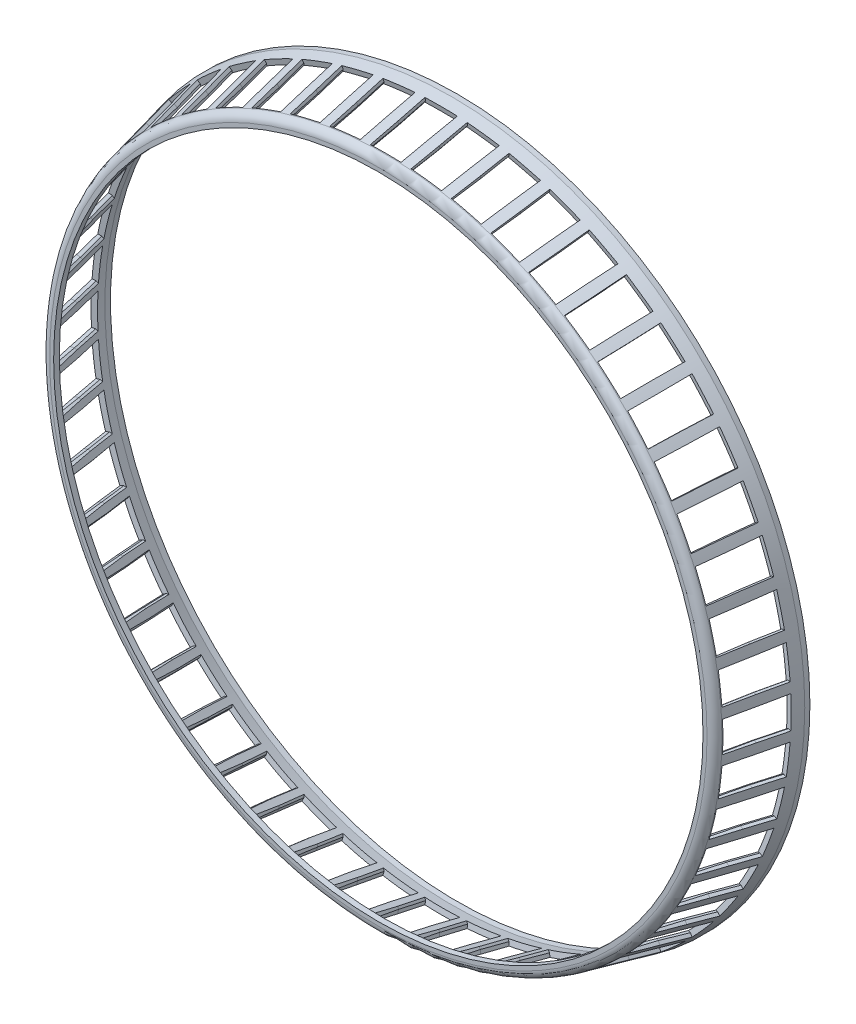
from build123d import *

# Parameters (mm, degrees)
SCHNITT_LINEAR_AUSTRAGEN1_DEPTH = 30
SCHNITT_LINEAR_AUSTRAGEN2_DEPTH = 30
KREISMUSTER1_COUNT              = 52
KREISMUSTER1_COPY_1_DEPTH       = 30
KREISMUSTER1_COPY_2_DEPTH       = 30
KREISMUSTER1_COPY_3_DEPTH       = 30
KREISMUSTER1_COPY_4_DEPTH       = 30
KREISMUSTER1_COPY_5_DEPTH       = 30
KREISMUSTER1_COPY_6_DEPTH       = 30
KREISMUSTER1_COPY_7_DEPTH       = 30
KREISMUSTER1_COPY_8_DEPTH       = 30
KREISMUSTER1_COPY_9_DEPTH       = 30
KREISMUSTER1_COPY_10_DEPTH      = 30
KREISMUSTER1_COPY_11_DEPTH      = 30
KREISMUSTER1_COPY_12_DEPTH      = 30
KREISMUSTER1_COPY_13_DEPTH      = 30
KREISMUSTER1_COPY_14_DEPTH      = 30
KREISMUSTER1_COPY_15_DEPTH      = 30
KREISMUSTER1_COPY_16_DEPTH      = 30
KREISMUSTER1_COPY_17_DEPTH      = 30
KREISMUSTER1_COPY_18_DEPTH      = 30
KREISMUSTER1_COPY_19_DEPTH      = 30
KREISMUSTER1_COPY_20_DEPTH      = 30
KREISMUSTER1_COPY_21_DEPTH      = 30
KREISMUSTER1_COPY_22_DEPTH      = 30
KREISMUSTER1_COPY_23_DEPTH      = 30
KREISMUSTER1_COPY_24_DEPTH      = 30
KREISMUSTER1_COPY_25_DEPTH      = 30
KREISMUSTER1_COPY_26_DEPTH      = 30
KREISMUSTER1_COPY_27_DEPTH      = 30
KREISMUSTER1_COPY_28_DEPTH      = 30
KREISMUSTER1_COPY_29_DEPTH      = 30
KREISMUSTER1_COPY_30_DEPTH      = 30
KREISMUSTER1_COPY_31_DEPTH      = 30
KREISMUSTER1_COPY_32_DEPTH      = 30
KREISMUSTER1_COPY_33_DEPTH      = 30
KREISMUSTER1_COPY_34_DEPTH      = 30
KREISMUSTER1_COPY_35_DEPTH      = 30
KREISMUSTER1_COPY_36_DEPTH      = 30
KREISMUSTER1_COPY_37_DEPTH      = 30
KREISMUSTER1_COPY_38_DEPTH      = 30
KREISMUSTER1_COPY_39_DEPTH      = 30
KREISMUSTER1_COPY_40_DEPTH      = 30
KREISMUSTER1_COPY_41_DEPTH      = 30
KREISMUSTER1_COPY_42_DEPTH      = 30
KREISMUSTER1_COPY_43_DEPTH      = 30
KREISMUSTER1_COPY_44_DEPTH      = 30
KREISMUSTER1_COPY_45_DEPTH      = 30
KREISMUSTER1_COPY_46_DEPTH      = 30
KREISMUSTER1_COPY_47_DEPTH      = 30
KREISMUSTER1_COPY_48_DEPTH      = 30
KREISMUSTER1_COPY_49_DEPTH      = 30
KREISMUSTER1_COPY_50_DEPTH      = 30
KREISMUSTER1_COPY_51_DEPTH      = 30


with BuildPart() as part:
    # Skizze1 → Rotation1 (revolve)
    with BuildSketch(Plane(origin=(0, 0, 0), x_dir=(0, 0, -1), z_dir=(1, 0, 0)), mode=Mode.PRIVATE) as rotation1_sk:
        with BuildLine():
            Line((0, 571), (0, 578.06846125))
            ThreePointArc((0, 578.06846125), (3.260877647, 587.4061808), (11.625734185, 592.684012222))
            Line((11.625734185, 592.684012222), (129.944276229, 620))
            Line((129.944276229, 620), (139, 620))
            Line((139, 620), (139, 610))
            Line((139, 610), (129.115586543, 610))
            Line((129.115586543, 610), (13.875244728, 583.394670741))
            ThreePointArc((13.875244728, 583.394670741), (11.086959216, 581.6353936), (10, 578.522820417))
            Line((10, 578.522820417), (10, 571))
            Line((10, 571), (0, 571))
        make_face()
    revolve(rotation1_sk.sketch.rotate(Axis((0, 0, 0), (0, 0, -1)), 90), axis=Axis((0, 0, 0), (0, 0, -1)))  # turned: the seam where the file's is

    # Skizze2 → Schnitt-Linear austragen1 (cut)
    with BuildSketch(Plane(origin=(0, 604.21422708, -61.56858167), x_dir=(-1, 0, 0), z_dir=(0, -0.974370065, -0.224951054))):
        Polygon((28.5, 50), (-28.5, 50), (-27.5, 0), (-27, -50), (27, -50), (27.5, 0), align=None)
    schnitt_linear_austragen1 = extrude(amount=SCHNITT_LINEAR_AUSTRAGEN1_DEPTH, mode=Mode.SUBTRACT)

    # Skizze3 → Schnitt-Linear austragen2 (cut)
    with BuildSketch(Plane(origin=(-254.402168774, 410.436910266, 94.756827044), x_dir=(0, 0.224951054, -0.974370065), z_dir=(0.516977448, -0.834059818, -0.192557881))):
        Polygon((245.909210342, 306.199136441), (145.909210342, 306.199136441), (145.909210342, 317.699136441), (195.909210342, 317.199136441), (245.909210342, 318.199136441), align=None)
    schnitt_linear_austragen2 = extrude(amount=SCHNITT_LINEAR_AUSTRAGEN2_DEPTH, mode=Mode.SUBTRACT)

    # Spiegeln2: Schnitt-Linear austragen2 across plane
    add(schnitt_linear_austragen2.mirror(Plane(origin=(0, 0, 0), x_dir=(0, 0, 1), z_dir=(1, 0, 0))), mode=Mode.SUBTRACT)

    # Kreismuster1: Schnitt-Linear austragen1, Schnitt-Linear austragen2 ×52 about axis
    kreismuster1_axis = Axis((0, 0, 0), (0, 0, 1))
    add([schnitt_linear_austragen1.rotate(kreismuster1_axis, i * 360 / KREISMUSTER1_COUNT) for i in range(1, KREISMUSTER1_COUNT)], mode=Mode.SUBTRACT)
    add([schnitt_linear_austragen2.rotate(kreismuster1_axis, i * 360 / KREISMUSTER1_COUNT) for i in range(1, KREISMUSTER1_COUNT)], mode=Mode.SUBTRACT)

    # Kreismuster1 copy 1 sketch → Kreismuster1 copy 1 (cut)
    with BuildSketch(Plane(origin=(203.074587914, 438.109155952, 94.756827044), x_dir=(-0.027114853, 0.223310908, -0.974370065), z_dir=(-0.412673299, -0.890293328, -0.192557881))):
        Polygon((245.909210342, -306.199136441), (145.909210342, -306.199136441), (145.909210342, -317.699136441), (195.909210342, -317.199136441), (245.909210342, -318.199136441), align=None)
    extrude(amount=KREISMUSTER1_COPY_1_DEPTH, mode=Mode.SUBTRACT)

    # Kreismuster1 copy 2 sketch → Kreismuster1 copy 2 (cut)
    with BuildSketch(Plane(origin=(148.785722278, 459.392783609, 94.756827044), x_dir=(-0.053834311, 0.218414386, -0.974370065), z_dir=(-0.302351444, -0.933544357, -0.192557881))):
        Polygon((245.909210342, -306.199136441), (145.909210342, -306.199136441), (145.909210342, -317.699136441), (195.909210342, -317.199136441), (245.909210342, -318.199136441), align=None)
    extrude(amount=KREISMUSTER1_COPY_2_DEPTH, mode=Mode.SUBTRACT)

    # Kreismuster1 copy 3 sketch → Kreismuster1 copy 3 (cut)
    with BuildSketch(Plane(origin=(92.327225775, 473.977430018, 94.756827044), x_dir=(-0.079768743, 0.21033289, -0.974370065), z_dir=(-0.187620624, -0.963182207, -0.192557881))):
        Polygon((245.909210342, -306.199136441), (145.909210342, -306.199136441), (145.909210342, -317.699136441), (195.909210342, -317.199136441), (245.909210342, -318.199136441), align=None)
    extrude(amount=KREISMUSTER1_COPY_3_DEPTH, mode=Mode.SUBTRACT)

    # Kreismuster1 copy 4 sketch → Kreismuster1 copy 4 (cut)
    with BuildSketch(Plane(origin=(34.522390417, 481.650418193, 94.756827044), x_dir=(-0.104539968, 0.199184267, -0.974370065), z_dir=(-0.070153872, -0.978774691, -0.192557881))):
        Polygon((245.909210342, -306.199136441), (145.909210342, -306.199136441), (145.909210342, -317.699136441), (195.909210342, -317.199136441), (245.909210342, -318.199136441), align=None)
    extrude(amount=KREISMUSTER1_COPY_4_DEPTH, mode=Mode.SUBTRACT)

    # Kreismuster1 copy 5 sketch → Kreismuster1 copy 5 (cut)
    with BuildSketch(Plane(origin=(-23.78585913, 482.299858688, 94.756827044), x_dir=(-0.127786764, 0.185131088, -0.974370065), z_dir=(0.04833588, -0.980094437, -0.192557881))):
        Polygon((245.909210342, -306.199136441), (145.909210342, -306.199136441), (145.909210342, -317.699136441), (195.909210342, -317.199136441), (245.909210342, -318.199136441), align=None)
    extrude(amount=KREISMUSTER1_COPY_5_DEPTH, mode=Mode.SUBTRACT)

    # Kreismuster1 copy 6 sketch → Kreismuster1 copy 6 (cut)
    with BuildSketch(Plane(origin=(-81.747257291, 475.9162812, 94.756827044), x_dir=(-0.149170141, 0.168378282, -0.974370065), z_dir=(0.166120787, -0.967122198, -0.192557881))):
        Polygon((245.909210342, -306.199136441), (145.909210342, -306.199136441), (145.909210342, -317.699136441), (195.909210342, -317.199136441), (245.909210342, -318.199136441), align=None)
    extrude(amount=KREISMUSTER1_COPY_6_DEPTH, mode=Mode.SUBTRACT)

    # Kreismuster1 copy 7 sketch → Kreismuster1 copy 7 (cut)
    with BuildSketch(Plane(origin=(-138.516596361, 462.592772661, 94.756827044), x_dir=(-0.168378282, 0.149170141, -0.974370065), z_dir=(0.281483279, -0.94004714, -0.192557881))):
        Polygon((245.909210342, -306.199136441), (145.909210342, -306.199136441), (145.909210342, -317.699136441), (195.909210342, -317.199136441), (245.909210342, -318.199136441), align=None)
    extrude(amount=KREISMUSTER1_COPY_7_DEPTH, mode=Mode.SUBTRACT)

    # Kreismuster1 copy 8 sketch → Kreismuster1 copy 8 (cut)
    with BuildSketch(Plane(origin=(-193.266051544, 442.523619828, 94.756827044), x_dir=(-0.185131088, 0.127786764, -0.974370065), z_dir=(0.39274111, -0.899264078, -0.192557881))):
        Polygon((245.909210342, -306.199136441), (145.909210342, -306.199136441), (145.909210342, -317.699136441), (195.909210342, -317.199136441), (245.909210342, -318.199136441), align=None)
    extrude(amount=KREISMUSTER1_COPY_8_DEPTH, mode=Mode.SUBTRACT)

    # Kreismuster1 copy 9 sketch → Kreismuster1 copy 9 (cut)
    with BuildSketch(Plane(origin=(-245.197252498, 416.001476143, 94.756827044), x_dir=(-0.199184267, 0.104539968, -0.974370065), z_dir=(0.498271892, -0.845367721, -0.192557881))):
        Polygon((245.909210342, -306.199136441), (145.909210342, -306.199136441), (145.909210342, -317.699136441), (195.909210342, -317.199136441), (245.909210342, -318.199136441), align=None)
    extrude(amount=KREISMUSTER1_COPY_9_DEPTH, mode=Mode.SUBTRACT)

    # Kreismuster1 copy 10 sketch → Kreismuster1 copy 10 (cut)
    with BuildSketch(Plane(origin=(-293.552925375, 383.413094181, 94.756827044), x_dir=(-0.21033289, 0.079768743, -0.974370065), z_dir=(0.596536748, -0.779143999, -0.192557881))):
        Polygon((245.909210342, -306.199136441), (145.909210342, -306.199136441), (145.909210342, -317.699136441), (195.909210342, -317.199136441), (245.909210342, -318.199136441), align=None)
    extrude(amount=KREISMUSTER1_COPY_10_DEPTH, mode=Mode.SUBTRACT)

    # Kreismuster1 copy 11 sketch → Kreismuster1 copy 11 (cut)
    with BuildSketch(Plane(origin=(-337.627935576, 345.233685935, 94.756827044), x_dir=(-0.218414386, 0.053834311, -0.974370065), z_dir=(0.686102754, -0.701558603, -0.192557881))):
        Polygon((245.909210342, -306.199136441), (145.909210342, -306.199136441), (145.909210342, -317.699136441), (195.909210342, -317.199136441), (245.909210342, -318.199136441), align=None)
    extrude(amount=KREISMUSTER1_COPY_11_DEPTH, mode=Mode.SUBTRACT)

    # Kreismuster1 copy 12 sketch → Kreismuster1 copy 12 (cut)
    with BuildSketch(Plane(origin=(-376.779570205, 302.019993149, 94.756827044), x_dir=(-0.223310908, 0.027114853, -0.974370065), z_dir=(0.765663838, -0.613742902, -0.192557881))):
        Polygon((245.909210342, -306.199136441), (145.909210342, -306.199136441), (145.909210342, -317.699136441), (195.909210342, -317.199136441), (245.909210342, -318.199136441), align=None)
    extrude(amount=KREISMUSTER1_COPY_12_DEPTH, mode=Mode.SUBTRACT)

    # Kreismuster1 copy 13 sketch → Kreismuster1 copy 13 (cut)
    with BuildSketch(Plane(origin=(-410.436910266, 254.402168774, 94.756827044), x_dir=(-0.224951054, 0, -0.974370065), z_dir=(0.834059818, -0.516977448, -0.192557881))):
        Polygon((245.909210342, -306.199136441), (145.909210342, -306.199136441), (145.909210342, -317.699136441), (195.909210342, -317.199136441), (245.909210342, -318.199136441), align=None)
    extrude(amount=KREISMUSTER1_COPY_13_DEPTH, mode=Mode.SUBTRACT)

    # Kreismuster1 copy 14 sketch → Kreismuster1 copy 14 (cut)
    with BuildSketch(Plane(origin=(-438.109155952, 203.074587914, 94.756827044), x_dir=(-0.223310908, -0.027114853, -0.974370065), z_dir=(0.890293328, -0.412673299, -0.192557881))):
        Polygon((245.909210342, -306.199136441), (145.909210342, -306.199136441), (145.909210342, -317.699136441), (195.909210342, -317.199136441), (245.909210342, -318.199136441), align=None)
    extrude(amount=KREISMUSTER1_COPY_14_DEPTH, mode=Mode.SUBTRACT)

    # Kreismuster1 copy 15 sketch → Kreismuster1 copy 15 (cut)
    with BuildSketch(Plane(origin=(-459.392783609, 148.785722278, 94.756827044), x_dir=(-0.218414386, -0.053834311, -0.974370065), z_dir=(0.933544357, -0.302351444, -0.192557881))):
        Polygon((245.909210342, -306.199136441), (145.909210342, -306.199136441), (145.909210342, -317.699136441), (195.909210342, -317.199136441), (245.909210342, -318.199136441), align=None)
    extrude(amount=KREISMUSTER1_COPY_15_DEPTH, mode=Mode.SUBTRACT)

    # Kreismuster1 copy 16 sketch → Kreismuster1 copy 16 (cut)
    with BuildSketch(Plane(origin=(-473.977430018, 92.327225775, 94.756827044), x_dir=(-0.21033289, -0.079768743, -0.974370065), z_dir=(0.963182207, -0.187620624, -0.192557881))):
        Polygon((245.909210342, -306.199136441), (145.909210342, -306.199136441), (145.909210342, -317.699136441), (195.909210342, -317.199136441), (245.909210342, -318.199136441), align=None)
    extrude(amount=KREISMUSTER1_COPY_16_DEPTH, mode=Mode.SUBTRACT)

    # Kreismuster1 copy 17 sketch → Kreismuster1 copy 17 (cut)
    with BuildSketch(Plane(origin=(-481.650418193, 34.522390417, 94.756827044), x_dir=(-0.199184267, -0.104539968, -0.974370065), z_dir=(0.978774691, -0.070153872, -0.192557881))):
        Polygon((245.909210342, -306.199136441), (145.909210342, -306.199136441), (145.909210342, -317.699136441), (195.909210342, -317.199136441), (245.909210342, -318.199136441), align=None)
    extrude(amount=KREISMUSTER1_COPY_17_DEPTH, mode=Mode.SUBTRACT)

    # Kreismuster1 copy 18 sketch → Kreismuster1 copy 18 (cut)
    with BuildSketch(Plane(origin=(-482.299858688, -23.78585913, 94.756827044), x_dir=(-0.185131088, -0.127786764, -0.974370065), z_dir=(0.980094437, 0.04833588, -0.192557881))):
        Polygon((245.909210342, -306.199136441), (145.909210342, -306.199136441), (145.909210342, -317.699136441), (195.909210342, -317.199136441), (245.909210342, -318.199136441), align=None)
    extrude(amount=KREISMUSTER1_COPY_18_DEPTH, mode=Mode.SUBTRACT)

    # Kreismuster1 copy 19 sketch → Kreismuster1 copy 19 (cut)
    with BuildSketch(Plane(origin=(-475.9162812, -81.747257291, 94.756827044), x_dir=(-0.168378282, -0.149170141, -0.974370065), z_dir=(0.967122198, 0.166120787, -0.192557881))):
        Polygon((245.909210342, -306.199136441), (145.909210342, -306.199136441), (145.909210342, -317.699136441), (195.909210342, -317.199136441), (245.909210342, -318.199136441), align=None)
    extrude(amount=KREISMUSTER1_COPY_19_DEPTH, mode=Mode.SUBTRACT)

    # Kreismuster1 copy 20 sketch → Kreismuster1 copy 20 (cut)
    with BuildSketch(Plane(origin=(-462.592772661, -138.516596361, 94.756827044), x_dir=(-0.149170141, -0.168378282, -0.974370065), z_dir=(0.94004714, 0.281483279, -0.192557881))):
        Polygon((245.909210342, -306.199136441), (145.909210342, -306.199136441), (145.909210342, -317.699136441), (195.909210342, -317.199136441), (245.909210342, -318.199136441), align=None)
    extrude(amount=KREISMUSTER1_COPY_20_DEPTH, mode=Mode.SUBTRACT)

    # Kreismuster1 copy 21 sketch → Kreismuster1 copy 21 (cut)
    with BuildSketch(Plane(origin=(-442.523619828, -193.266051544, 94.756827044), x_dir=(-0.127786764, -0.185131088, -0.974370065), z_dir=(0.899264078, 0.39274111, -0.192557881))):
        Polygon((245.909210342, -306.199136441), (145.909210342, -306.199136441), (145.909210342, -317.699136441), (195.909210342, -317.199136441), (245.909210342, -318.199136441), align=None)
    extrude(amount=KREISMUSTER1_COPY_21_DEPTH, mode=Mode.SUBTRACT)

    # Kreismuster1 copy 22 sketch → Kreismuster1 copy 22 (cut)
    with BuildSketch(Plane(origin=(-416.001476143, -245.197252498, 94.756827044), x_dir=(-0.104539968, -0.199184267, -0.974370065), z_dir=(0.845367721, 0.498271892, -0.192557881))):
        Polygon((245.909210342, -306.199136441), (145.909210342, -306.199136441), (145.909210342, -317.699136441), (195.909210342, -317.199136441), (245.909210342, -318.199136441), align=None)
    extrude(amount=KREISMUSTER1_COPY_22_DEPTH, mode=Mode.SUBTRACT)

    # Kreismuster1 copy 23 sketch → Kreismuster1 copy 23 (cut)
    with BuildSketch(Plane(origin=(-383.413094181, -293.552925375, 94.756827044), x_dir=(-0.079768743, -0.21033289, -0.974370065), z_dir=(0.779143999, 0.596536748, -0.192557881))):
        Polygon((245.909210342, -306.199136441), (145.909210342, -306.199136441), (145.909210342, -317.699136441), (195.909210342, -317.199136441), (245.909210342, -318.199136441), align=None)
    extrude(amount=KREISMUSTER1_COPY_23_DEPTH, mode=Mode.SUBTRACT)

    # Kreismuster1 copy 24 sketch → Kreismuster1 copy 24 (cut)
    with BuildSketch(Plane(origin=(-345.233685935, -337.627935576, 94.756827044), x_dir=(-0.053834311, -0.218414386, -0.974370065), z_dir=(0.701558603, 0.686102754, -0.192557881))):
        Polygon((245.909210342, -306.199136441), (145.909210342, -306.199136441), (145.909210342, -317.699136441), (195.909210342, -317.199136441), (245.909210342, -318.199136441), align=None)
    extrude(amount=KREISMUSTER1_COPY_24_DEPTH, mode=Mode.SUBTRACT)

    # Kreismuster1 copy 25 sketch → Kreismuster1 copy 25 (cut)
    with BuildSketch(Plane(origin=(-302.019993149, -376.779570205, 94.756827044), x_dir=(-0.027114853, -0.223310908, -0.974370065), z_dir=(0.613742902, 0.765663838, -0.192557881))):
        Polygon((245.909210342, -306.199136441), (145.909210342, -306.199136441), (145.909210342, -317.699136441), (195.909210342, -317.199136441), (245.909210342, -318.199136441), align=None)
    extrude(amount=KREISMUSTER1_COPY_25_DEPTH, mode=Mode.SUBTRACT)

    # Kreismuster1 copy 26 sketch → Kreismuster1 copy 26 (cut)
    with BuildSketch(Plane(origin=(-254.402168774, -410.436910266, 94.756827044), x_dir=(0, -0.224951054, -0.974370065), z_dir=(0.516977448, 0.834059818, -0.192557881))):
        Polygon((245.909210342, -306.199136441), (145.909210342, -306.199136441), (145.909210342, -317.699136441), (195.909210342, -317.199136441), (245.909210342, -318.199136441), align=None)
    extrude(amount=KREISMUSTER1_COPY_26_DEPTH, mode=Mode.SUBTRACT)

    # Kreismuster1 copy 27 sketch → Kreismuster1 copy 27 (cut)
    with BuildSketch(Plane(origin=(-203.074587914, -438.109155952, 94.756827044), x_dir=(0.027114853, -0.223310908, -0.974370065), z_dir=(0.412673299, 0.890293328, -0.192557881))):
        Polygon((245.909210342, -306.199136441), (145.909210342, -306.199136441), (145.909210342, -317.699136441), (195.909210342, -317.199136441), (245.909210342, -318.199136441), align=None)
    extrude(amount=KREISMUSTER1_COPY_27_DEPTH, mode=Mode.SUBTRACT)

    # Kreismuster1 copy 28 sketch → Kreismuster1 copy 28 (cut)
    with BuildSketch(Plane(origin=(-148.785722278, -459.392783609, 94.756827044), x_dir=(0.053834311, -0.218414386, -0.974370065), z_dir=(0.302351444, 0.933544357, -0.192557881))):
        Polygon((245.909210342, -306.199136441), (145.909210342, -306.199136441), (145.909210342, -317.699136441), (195.909210342, -317.199136441), (245.909210342, -318.199136441), align=None)
    extrude(amount=KREISMUSTER1_COPY_28_DEPTH, mode=Mode.SUBTRACT)

    # Kreismuster1 copy 29 sketch → Kreismuster1 copy 29 (cut)
    with BuildSketch(Plane(origin=(-92.327225775, -473.977430018, 94.756827044), x_dir=(0.079768743, -0.21033289, -0.974370065), z_dir=(0.187620624, 0.963182207, -0.192557881))):
        Polygon((245.909210342, -306.199136441), (145.909210342, -306.199136441), (145.909210342, -317.699136441), (195.909210342, -317.199136441), (245.909210342, -318.199136441), align=None)
    extrude(amount=KREISMUSTER1_COPY_29_DEPTH, mode=Mode.SUBTRACT)

    # Kreismuster1 copy 30 sketch → Kreismuster1 copy 30 (cut)
    with BuildSketch(Plane(origin=(-34.522390417, -481.650418193, 94.756827044), x_dir=(0.104539968, -0.199184267, -0.974370065), z_dir=(0.070153872, 0.978774691, -0.192557881))):
        Polygon((245.909210342, -306.199136441), (145.909210342, -306.199136441), (145.909210342, -317.699136441), (195.909210342, -317.199136441), (245.909210342, -318.199136441), align=None)
    extrude(amount=KREISMUSTER1_COPY_30_DEPTH, mode=Mode.SUBTRACT)

    # Kreismuster1 copy 31 sketch → Kreismuster1 copy 31 (cut)
    with BuildSketch(Plane(origin=(23.78585913, -482.299858688, 94.756827044), x_dir=(0.127786764, -0.185131088, -0.974370065), z_dir=(-0.04833588, 0.980094437, -0.192557881))):
        Polygon((245.909210342, -306.199136441), (145.909210342, -306.199136441), (145.909210342, -317.699136441), (195.909210342, -317.199136441), (245.909210342, -318.199136441), align=None)
    extrude(amount=KREISMUSTER1_COPY_31_DEPTH, mode=Mode.SUBTRACT)

    # Kreismuster1 copy 32 sketch → Kreismuster1 copy 32 (cut)
    with BuildSketch(Plane(origin=(81.747257291, -475.9162812, 94.756827044), x_dir=(0.149170141, -0.168378282, -0.974370065), z_dir=(-0.166120787, 0.967122198, -0.192557881))):
        Polygon((245.909210342, -306.199136441), (145.909210342, -306.199136441), (145.909210342, -317.699136441), (195.909210342, -317.199136441), (245.909210342, -318.199136441), align=None)
    extrude(amount=KREISMUSTER1_COPY_32_DEPTH, mode=Mode.SUBTRACT)

    # Kreismuster1 copy 33 sketch → Kreismuster1 copy 33 (cut)
    with BuildSketch(Plane(origin=(138.516596361, -462.592772661, 94.756827044), x_dir=(0.168378282, -0.149170141, -0.974370065), z_dir=(-0.281483279, 0.94004714, -0.192557881))):
        Polygon((245.909210342, -306.199136441), (145.909210342, -306.199136441), (145.909210342, -317.699136441), (195.909210342, -317.199136441), (245.909210342, -318.199136441), align=None)
    extrude(amount=KREISMUSTER1_COPY_33_DEPTH, mode=Mode.SUBTRACT)

    # Kreismuster1 copy 34 sketch → Kreismuster1 copy 34 (cut)
    with BuildSketch(Plane(origin=(193.266051544, -442.523619828, 94.756827044), x_dir=(0.185131088, -0.127786764, -0.974370065), z_dir=(-0.39274111, 0.899264078, -0.192557881))):
        Polygon((245.909210342, -306.199136441), (145.909210342, -306.199136441), (145.909210342, -317.699136441), (195.909210342, -317.199136441), (245.909210342, -318.199136441), align=None)
    extrude(amount=KREISMUSTER1_COPY_34_DEPTH, mode=Mode.SUBTRACT)

    # Kreismuster1 copy 35 sketch → Kreismuster1 copy 35 (cut)
    with BuildSketch(Plane(origin=(245.197252498, -416.001476143, 94.756827044), x_dir=(0.199184267, -0.104539968, -0.974370065), z_dir=(-0.498271892, 0.845367721, -0.192557881))):
        Polygon((245.909210342, -306.199136441), (145.909210342, -306.199136441), (145.909210342, -317.699136441), (195.909210342, -317.199136441), (245.909210342, -318.199136441), align=None)
    extrude(amount=KREISMUSTER1_COPY_35_DEPTH, mode=Mode.SUBTRACT)

    # Kreismuster1 copy 36 sketch → Kreismuster1 copy 36 (cut)
    with BuildSketch(Plane(origin=(293.552925375, -383.413094181, 94.756827044), x_dir=(0.21033289, -0.079768743, -0.974370065), z_dir=(-0.596536748, 0.779143999, -0.192557881))):
        Polygon((245.909210342, -306.199136441), (145.909210342, -306.199136441), (145.909210342, -317.699136441), (195.909210342, -317.199136441), (245.909210342, -318.199136441), align=None)
    extrude(amount=KREISMUSTER1_COPY_36_DEPTH, mode=Mode.SUBTRACT)

    # Kreismuster1 copy 37 sketch → Kreismuster1 copy 37 (cut)
    with BuildSketch(Plane(origin=(337.627935576, -345.233685935, 94.756827044), x_dir=(0.218414386, -0.053834311, -0.974370065), z_dir=(-0.686102754, 0.701558603, -0.192557881))):
        Polygon((245.909210342, -306.199136441), (145.909210342, -306.199136441), (145.909210342, -317.699136441), (195.909210342, -317.199136441), (245.909210342, -318.199136441), align=None)
    extrude(amount=KREISMUSTER1_COPY_37_DEPTH, mode=Mode.SUBTRACT)

    # Kreismuster1 copy 38 sketch → Kreismuster1 copy 38 (cut)
    with BuildSketch(Plane(origin=(376.779570205, -302.019993149, 94.756827044), x_dir=(0.223310908, -0.027114853, -0.974370065), z_dir=(-0.765663838, 0.613742902, -0.192557881))):
        Polygon((245.909210342, -306.199136441), (145.909210342, -306.199136441), (145.909210342, -317.699136441), (195.909210342, -317.199136441), (245.909210342, -318.199136441), align=None)
    extrude(amount=KREISMUSTER1_COPY_38_DEPTH, mode=Mode.SUBTRACT)

    # Kreismuster1 copy 39 sketch → Kreismuster1 copy 39 (cut)
    with BuildSketch(Plane(origin=(410.436910266, -254.402168774, 94.756827044), x_dir=(0.224951054, 0, -0.974370065), z_dir=(-0.834059818, 0.516977448, -0.192557881))):
        Polygon((245.909210342, -306.199136441), (145.909210342, -306.199136441), (145.909210342, -317.699136441), (195.909210342, -317.199136441), (245.909210342, -318.199136441), align=None)
    extrude(amount=KREISMUSTER1_COPY_39_DEPTH, mode=Mode.SUBTRACT)

    # Kreismuster1 copy 40 sketch → Kreismuster1 copy 40 (cut)
    with BuildSketch(Plane(origin=(438.109155952, -203.074587914, 94.756827044), x_dir=(0.223310908, 0.027114853, -0.974370065), z_dir=(-0.890293328, 0.412673299, -0.192557881))):
        Polygon((245.909210342, -306.199136441), (145.909210342, -306.199136441), (145.909210342, -317.699136441), (195.909210342, -317.199136441), (245.909210342, -318.199136441), align=None)
    extrude(amount=KREISMUSTER1_COPY_40_DEPTH, mode=Mode.SUBTRACT)

    # Kreismuster1 copy 41 sketch → Kreismuster1 copy 41 (cut)
    with BuildSketch(Plane(origin=(459.392783609, -148.785722278, 94.756827044), x_dir=(0.218414386, 0.053834311, -0.974370065), z_dir=(-0.933544357, 0.302351444, -0.192557881))):
        Polygon((245.909210342, -306.199136441), (145.909210342, -306.199136441), (145.909210342, -317.699136441), (195.909210342, -317.199136441), (245.909210342, -318.199136441), align=None)
    extrude(amount=KREISMUSTER1_COPY_41_DEPTH, mode=Mode.SUBTRACT)

    # Kreismuster1 copy 42 sketch → Kreismuster1 copy 42 (cut)
    with BuildSketch(Plane(origin=(473.977430018, -92.327225775, 94.756827044), x_dir=(0.21033289, 0.079768743, -0.974370065), z_dir=(-0.963182207, 0.187620624, -0.192557881))):
        Polygon((245.909210342, -306.199136441), (145.909210342, -306.199136441), (145.909210342, -317.699136441), (195.909210342, -317.199136441), (245.909210342, -318.199136441), align=None)
    extrude(amount=KREISMUSTER1_COPY_42_DEPTH, mode=Mode.SUBTRACT)

    # Kreismuster1 copy 43 sketch → Kreismuster1 copy 43 (cut)
    with BuildSketch(Plane(origin=(481.650418193, -34.522390417, 94.756827044), x_dir=(0.199184267, 0.104539968, -0.974370065), z_dir=(-0.978774691, 0.070153872, -0.192557881))):
        Polygon((245.909210342, -306.199136441), (145.909210342, -306.199136441), (145.909210342, -317.699136441), (195.909210342, -317.199136441), (245.909210342, -318.199136441), align=None)
    extrude(amount=KREISMUSTER1_COPY_43_DEPTH, mode=Mode.SUBTRACT)

    # Kreismuster1 copy 44 sketch → Kreismuster1 copy 44 (cut)
    with BuildSketch(Plane(origin=(482.299858688, 23.78585913, 94.756827044), x_dir=(0.185131088, 0.127786764, -0.974370065), z_dir=(-0.980094437, -0.04833588, -0.192557881))):
        Polygon((245.909210342, -306.199136441), (145.909210342, -306.199136441), (145.909210342, -317.699136441), (195.909210342, -317.199136441), (245.909210342, -318.199136441), align=None)
    extrude(amount=KREISMUSTER1_COPY_44_DEPTH, mode=Mode.SUBTRACT)

    # Kreismuster1 copy 45 sketch → Kreismuster1 copy 45 (cut)
    with BuildSketch(Plane(origin=(475.9162812, 81.747257291, 94.756827044), x_dir=(0.168378282, 0.149170141, -0.974370065), z_dir=(-0.967122198, -0.166120787, -0.192557881))):
        Polygon((245.909210342, -306.199136441), (145.909210342, -306.199136441), (145.909210342, -317.699136441), (195.909210342, -317.199136441), (245.909210342, -318.199136441), align=None)
    extrude(amount=KREISMUSTER1_COPY_45_DEPTH, mode=Mode.SUBTRACT)

    # Kreismuster1 copy 46 sketch → Kreismuster1 copy 46 (cut)
    with BuildSketch(Plane(origin=(462.592772661, 138.516596361, 94.756827044), x_dir=(0.149170141, 0.168378282, -0.974370065), z_dir=(-0.94004714, -0.281483279, -0.192557881))):
        Polygon((245.909210342, -306.199136441), (145.909210342, -306.199136441), (145.909210342, -317.699136441), (195.909210342, -317.199136441), (245.909210342, -318.199136441), align=None)
    extrude(amount=KREISMUSTER1_COPY_46_DEPTH, mode=Mode.SUBTRACT)

    # Kreismuster1 copy 47 sketch → Kreismuster1 copy 47 (cut)
    with BuildSketch(Plane(origin=(442.523619828, 193.266051544, 94.756827044), x_dir=(0.127786764, 0.185131088, -0.974370065), z_dir=(-0.899264078, -0.39274111, -0.192557881))):
        Polygon((245.909210342, -306.199136441), (145.909210342, -306.199136441), (145.909210342, -317.699136441), (195.909210342, -317.199136441), (245.909210342, -318.199136441), align=None)
    extrude(amount=KREISMUSTER1_COPY_47_DEPTH, mode=Mode.SUBTRACT)

    # Kreismuster1 copy 48 sketch → Kreismuster1 copy 48 (cut)
    with BuildSketch(Plane(origin=(416.001476143, 245.197252498, 94.756827044), x_dir=(0.104539968, 0.199184267, -0.974370065), z_dir=(-0.845367721, -0.498271892, -0.192557881))):
        Polygon((245.909210342, -306.199136441), (145.909210342, -306.199136441), (145.909210342, -317.699136441), (195.909210342, -317.199136441), (245.909210342, -318.199136441), align=None)
    extrude(amount=KREISMUSTER1_COPY_48_DEPTH, mode=Mode.SUBTRACT)

    # Kreismuster1 copy 49 sketch → Kreismuster1 copy 49 (cut)
    with BuildSketch(Plane(origin=(383.413094181, 293.552925375, 94.756827044), x_dir=(0.079768743, 0.21033289, -0.974370065), z_dir=(-0.779143999, -0.596536748, -0.192557881))):
        Polygon((245.909210342, -306.199136441), (145.909210342, -306.199136441), (145.909210342, -317.699136441), (195.909210342, -317.199136441), (245.909210342, -318.199136441), align=None)
    extrude(amount=KREISMUSTER1_COPY_49_DEPTH, mode=Mode.SUBTRACT)

    # Kreismuster1 copy 50 sketch → Kreismuster1 copy 50 (cut)
    with BuildSketch(Plane(origin=(345.233685935, 337.627935576, 94.756827044), x_dir=(0.053834311, 0.218414386, -0.974370065), z_dir=(-0.701558603, -0.686102754, -0.192557881))):
        Polygon((245.909210342, -306.199136441), (145.909210342, -306.199136441), (145.909210342, -317.699136441), (195.909210342, -317.199136441), (245.909210342, -318.199136441), align=None)
    extrude(amount=KREISMUSTER1_COPY_50_DEPTH, mode=Mode.SUBTRACT)

    # Kreismuster1 copy 51 sketch → Kreismuster1 copy 51 (cut)
    with BuildSketch(Plane(origin=(302.019993149, 376.779570205, 94.756827044), x_dir=(0.027114853, 0.223310908, -0.974370065), z_dir=(-0.613742902, -0.765663838, -0.192557881))):
        Polygon((245.909210342, -306.199136441), (145.909210342, -306.199136441), (145.909210342, -317.699136441), (195.909210342, -317.199136441), (245.909210342, -318.199136441), align=None)
    extrude(amount=KREISMUSTER1_COPY_51_DEPTH, mode=Mode.SUBTRACT)


solid = part.part
